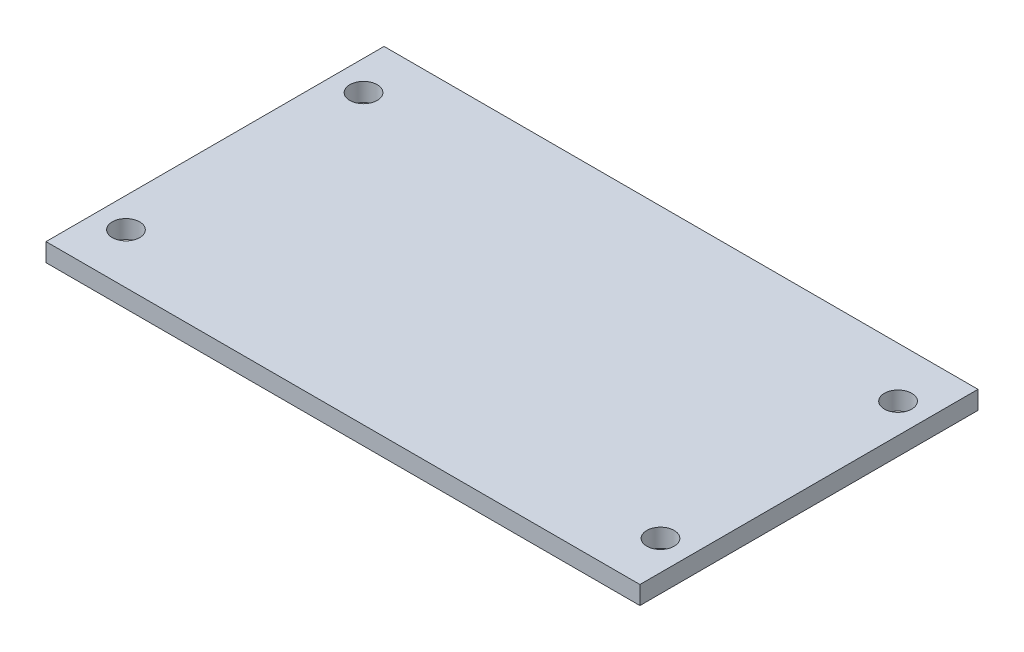
from build123d import *

# Parameters (mm, degrees)
BOSS_EXTRUDE1_DEPTH = 10
SKETCH3_W           = 65
SKETCH3_H           = 37
BOSS_EXTRUDE2_DEPTH = 2
SKETCH4_R           = 1.5
CUT_EXTRUDE1_DEPTH  = 5


with BuildPart() as part:
    # Sketch2 → Boss-Extrude1 (new body)
    with BuildSketch(Plane.XY):
        Polygon((-17.5, 0), (-17.5, -1), (-14.5, -1), (-14.5, -5), (-22.5, -5), (-22.5, 0), (-22.5, 4), (22.5, 4), (22.5, -5), (14.5, -5), (14.5, -1), (17.5, -1), (17.5, 0), align=None)
    extrude(amount=BOSS_EXTRUDE1_DEPTH)

    # Sketch3 → Boss-Extrude2 (add)
    with BuildSketch(Plane(origin=(0, 4, 0), x_dir=(1, 0, 0), z_dir=(0, 1, 0))):
        with Locations((0, -5)):
            Rectangle(SKETCH3_W, SKETCH3_H)
    extrude(amount=BOSS_EXTRUDE2_DEPTH)

    # Sketch4 → Cut-Extrude1 (cut)
    with BuildSketch(Plane(origin=(0, 6, 0), x_dir=(1, 0, 0), z_dir=(0, 1, 0))):
        with Locations((-29.25, 8)):
            Circle(SKETCH4_R)
        with Locations((-29.25, -18)):
            Circle(SKETCH4_R)
        with Locations((29.25, -18)):
            Circle(SKETCH4_R)
        with Locations((29.25, 8)):
            Circle(SKETCH4_R)
    extrude(amount=-CUT_EXTRUDE1_DEPTH, mode=Mode.SUBTRACT)


solid = part.part
